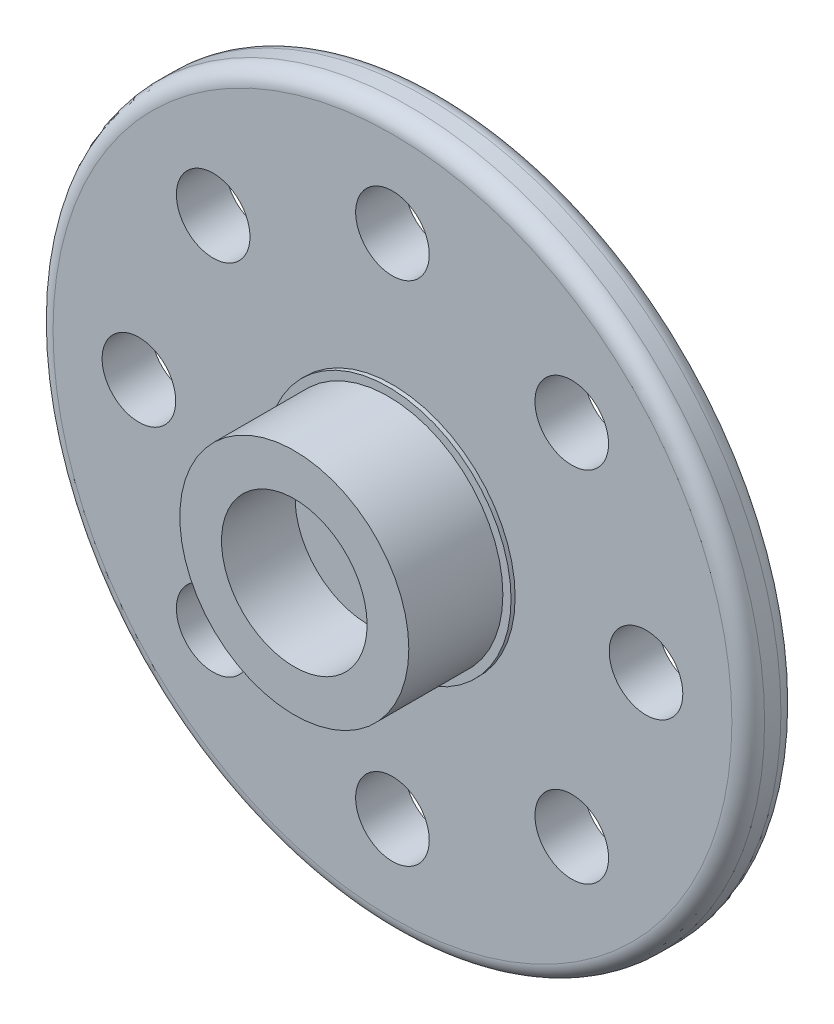
from build123d import *

# Parameters (mm, degrees)
SKETCH1_R           = 217.5
BOSS_EXTRUDE1_DEPTH = 30
SKETCH2_R           = 75
BOSS_EXTRUDE2_DEPTH = 2.5
SKETCH3_R           = 70
BOSS_EXTRUDE3_DEPTH = 57.5
SKETCH12_R          = 22.5
CUT_EXTRUDE2_DEPTH  = 30
FILLET2_R           = 10
SCALE2_SCALE        = 0.1
SKETCH14_R          = 4.45
CUT_EXTRUDE3_DEPTH  = 4.5


with BuildPart() as part:
    # Sketch1 → Boss-Extrude1 (new body)
    with BuildSketch(Plane.XY):
        Circle(SKETCH1_R)
    extrude(amount=BOSS_EXTRUDE1_DEPTH)

    # Sketch2 → Boss-Extrude2 (add)
    with BuildSketch(Plane.XY.offset(30)):
        Circle(SKETCH2_R)
    extrude(amount=BOSS_EXTRUDE2_DEPTH)

    # Sketch3 → Boss-Extrude3 (add)
    with BuildSketch(Plane.XY.offset(32.5)):
        Circle(SKETCH3_R)
    extrude(amount=BOSS_EXTRUDE3_DEPTH)

    # Sketch12 → Cut-Extrude2 (cut)
    with BuildSketch(Plane.XY.offset(30)):
        with Locations((0, 155)):
            Circle(SKETCH12_R)
        with Locations((109.601551084, 109.601551084)):
            Circle(SKETCH12_R)
        with Locations((155, 0)):
            Circle(SKETCH12_R)
        with Locations((109.601551084, -109.601551084)):
            Circle(SKETCH12_R)
        with Locations((0, -155)):
            Circle(SKETCH12_R)
        with Locations((-109.601551084, -109.601551084)):
            Circle(SKETCH12_R)
        with Locations((-155, 0)):
            Circle(SKETCH12_R)
        with Locations((-109.601551084, 109.601551084)):
            Circle(SKETCH12_R)
    extrude(amount=-CUT_EXTRUDE2_DEPTH, mode=Mode.SUBTRACT)

    # Fillet2
    fillet2_edges = [part.edges().sort_by_distance(p)[0] for p in [
        (-217.5, 0, 0),
        (-217.5, 0, 30),
    ]]
    fillet(fillet2_edges, radius=FILLET2_R)


with BuildPart() as part_1:
    # Scale2: scaled about (0, 0, 23.418586113)
    add(part.part.scale(SCALE2_SCALE).moved(Location((0, 0, 21.076727502))))

    # Sketch14 → Cut-Extrude3 (cut)
    with BuildSketch(Plane.XY.offset(30.076727502)):
        Circle(SKETCH14_R)
    extrude(amount=-CUT_EXTRUDE3_DEPTH, mode=Mode.SUBTRACT)


solid = part_1.part
